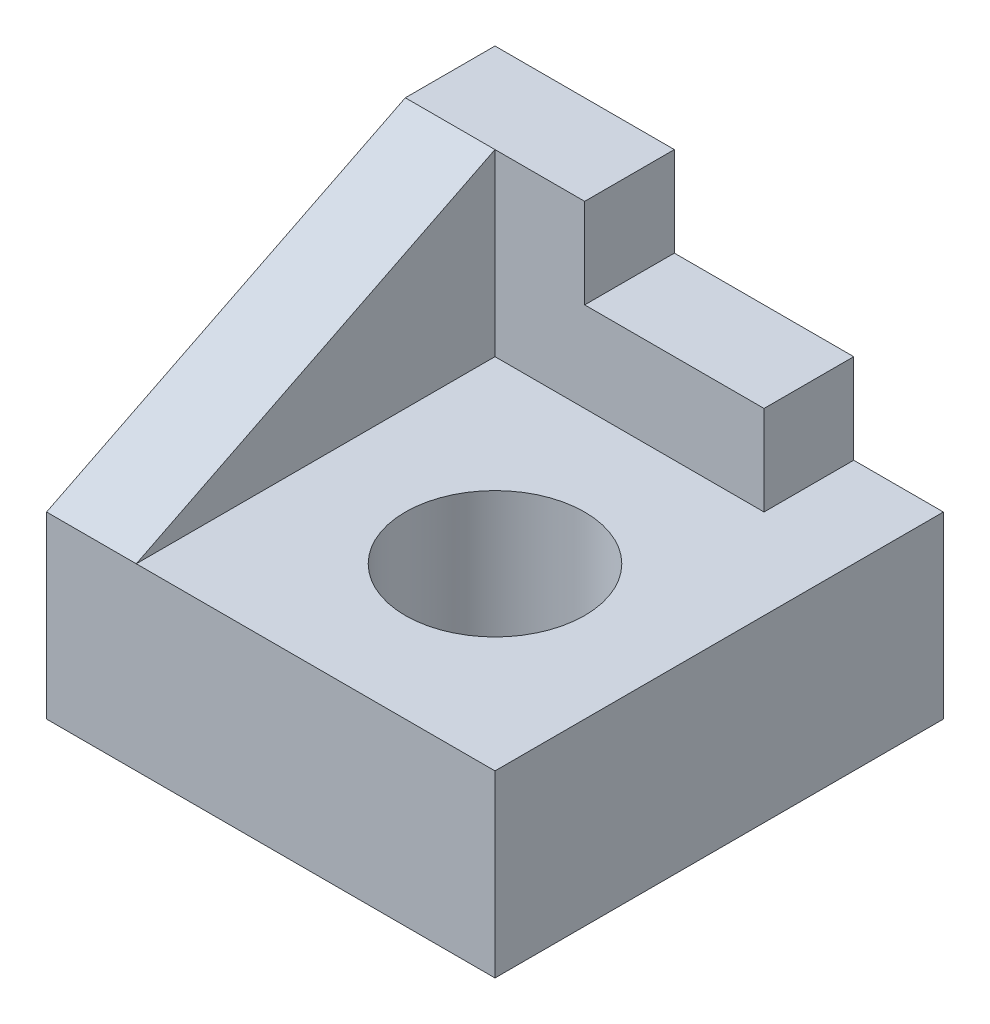
from build123d import *

# Parameters (mm, degrees)
SKETCH_1_R          = 5
EXTRUDE_1_DEPTH     = 10
SKETCH_1_3_W        = 10
SKETCH_1_3_H        = 5
EXTRUDE_2_DEPTH     = 15
EXTRUDE_3_DEPTH     = 20
CUT_EXTRUDE_1_DEPTH = 20
SCALE_1_SCALE       = 0.2


with BuildPart() as part:
    # 草圖1 → 填料-伸長1 (new body)
    with BuildSketch(Plane(origin=(0, 0, 0), x_dir=(1, 0, 0), z_dir=(0, 1, 0))):
        Polygon((10, 15), (5, 15), (5, 10), (-5, 10), (-10, 10), (-10, -10), (10, -10), align=None)
        Circle(SKETCH_1_R, mode=Mode.SUBTRACT)
    extrude(amount=EXTRUDE_1_DEPTH)

    # 草圖1<3> → 填料-伸長2 (add)
    with BuildSketch(Plane(origin=(0, 0, 0), x_dir=(1, 0, 0), z_dir=(0, 1, 0))):
        with Locations((0, 12.5)):
            Rectangle(SKETCH_1_3_W, SKETCH_1_3_H)
    extrude(amount=EXTRUDE_2_DEPTH)

    # 草圖1<4> → 填料-伸長3 (add)
    with BuildSketch(Plane(origin=(0, 0, 0), x_dir=(1, 0, 0), z_dir=(0, 1, 0))):
        Polygon((-5, 15), (-15, 15), (-15, -10), (-10, -10), (-10, 10), (-5, 10), align=None)
    extrude(amount=EXTRUDE_3_DEPTH)

    # 草圖2 → 除料-伸長1 (cut)
    with BuildSketch(Plane(origin=(-10, 0, 0), x_dir=(0, 0, -1), z_dir=(1, 0, 0))):
        Polygon((-10, 10), (10, 20), (-10, 20), align=None)
    extrude(amount=-CUT_EXTRUDE_1_DEPTH, mode=Mode.SUBTRACT)


with BuildPart() as part_1:
    # 縮放比例1: scaled about (-4.00247113, 6.644426123, -3.971444222)
    add(part.part.scale(SCALE_1_SCALE).moved(Location((-3.201976904, 5.315540898, -3.177155378))))


solid = part_1.part
